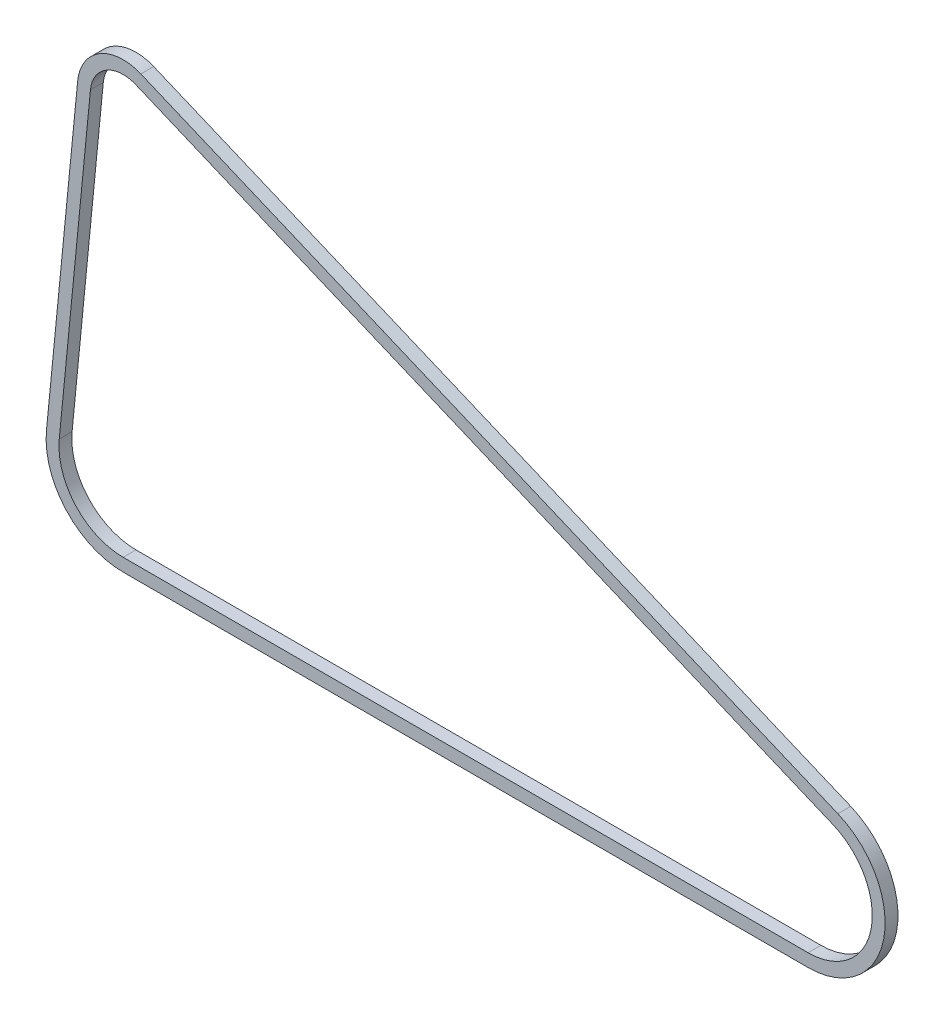
from build123d import *

# Parameters (mm, degrees)
BOSS_EXTRUDE1_DEPTH = 1.27


with BuildPart() as part:
    # Sketch3 → Boss-Extrude1 (new body, symmetric)
    with BuildSketch(Plane.XY):
        with BuildLine():
            Line((5.890966214, 14.05539459), (-131.972287758, 71.837320675))
            ThreePointArc((-131.972287758, 71.837320675), (-140.099400595, 71.262691308), (-144.46347369, 64.382645669))
            Line((-144.46347369, 64.382645669), (-150.633850189, 1.488))
            ThreePointArc((-150.633850189, 1.488), (-146.756811041, -10.236710409), (-135.466666667, -15.24))
            Line((-135.466666667, -15.24), (0, -15.24))
            ThreePointArc((0, -15.24), (14.940913853, -3.004445577), (5.890966214, 14.05539459))
        make_face()
        with BuildLine():
            Line((-141.93560977, 64.134645669), (-148.105986269, 1.24))
            ThreePointArc((-148.105986269, 1.24), (-144.875120312, -8.530592008), (-135.466666667, -12.7))
            Line((-135.466666667, -12.7), (0, -12.7))
            ThreePointArc((0, -12.7), (12.450761544, -2.503704648), (4.909138512, 11.712828825))
            Line((4.909138512, 11.712828825), (-132.95411546, 69.49475491))
            ThreePointArc((-132.95411546, 69.49475491), (-138.797725354, 69.08158114), (-141.93560977, 64.134645669))
        make_face(mode=Mode.SUBTRACT)
    extrude(amount=BOSS_EXTRUDE1_DEPTH, both=True)


solid = part.part
